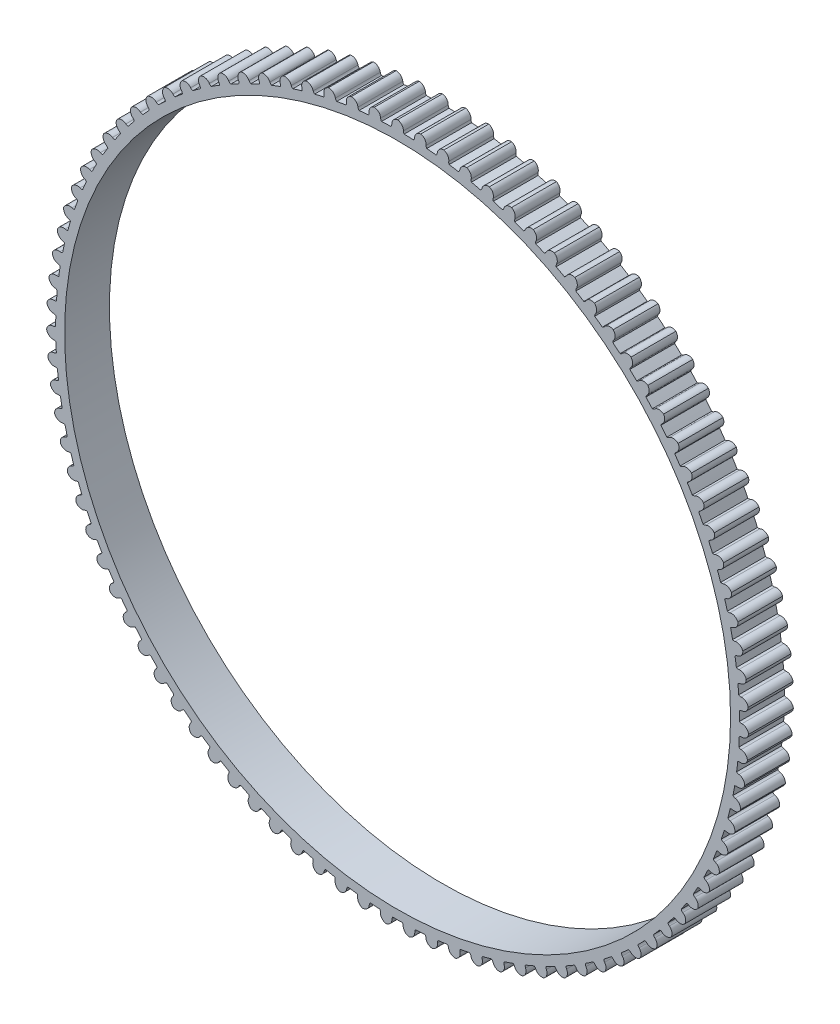
from build123d import *

# Parameters (mm, degrees)
SKETCH1_R      = 44.5516
EXTRUDE1_DEPTH = 6


with BuildPart() as part:
    # Sketch1 → Extrude1 (new body)
    with BuildSketch(Plane.XY):
        with BuildLine():
            ThreePointArc((1.512467656, 45.720390011), (1.196213111, 45.729757219), (0.879901343, 45.736936876))
            ThreePointArc((0.879901343, 45.736936876), (0.802731173, 45.892155239), (0.777675809, 46.063678427))
            ThreePointArc((0.777675809, 46.063678427), (0.559737338, 46.661659663), (0, 46.9646))
            ThreePointArc((0, 46.9646), (-0.559737396, 46.661659691), (-0.777675895, 46.063678426))
            ThreePointArc((-0.777675895, 46.063678426), (-0.802731266, 45.892155234), (-0.879901451, 45.736936874))
            ThreePointArc((-0.879901451, 45.736936874), (-1.196213165, 45.729757218), (-1.512467656, 45.720390011))
            ThreePointArc((-1.512467656, 45.720390011), (-1.828679241, 45.708834522), (-2.144803332, 45.695092076))
            ThreePointArc((-2.144803332, 45.695092076), (-2.232063251, 45.844870852), (-2.268399903, 46.014363103))
            ThreePointArc((-2.268399903, 46.014363103), (-2.525382809, 46.596633248), (-3.103917856, 46.861917877))
            ThreePointArc((-3.103917856, 46.861917877), (-3.642409955, 46.522646537), (-3.820351029, 45.911568999))
            ThreePointArc((-3.820351029, 45.911568999), (-3.834015551, 45.738764897), (-3.900758541, 45.578785679))
            ThreePointArc((-3.900758541, 45.578785679), (-4.215933462, 45.550713784), (-4.53090667, 45.520462497))
            ThreePointArc((-4.53090667, 45.520462497), (-4.845633899, 45.488036375), (-5.160129329, 45.453434265))
            ThreePointArc((-5.160129329, 45.453434265), (-5.257097432, 45.59711851), (-5.304556481, 45.763838676))
            ThreePointArc((-5.304556481, 45.763838676), (-5.5994601, 46.327851612), (-6.19426307, 46.55432051))
            ThreePointArc((-6.19426307, 46.55432051), (-6.709155184, 46.180201686), (-6.84632074, 45.558699963))
            ThreePointArc((-6.84632074, 45.558699963), (-6.848534662, 45.385370578), (-6.904558608, 45.221330051))
            ThreePointArc((-6.904558608, 45.221330051), (-7.21718915, 45.172489437), (-7.529474384, 45.121487527))
            ThreePointArc((-7.529474384, 45.121487527), (-7.84137044, 45.068331795), (-8.152891393, 45.013020151))
            ThreePointArc((-8.152891393, 45.013020151), (-8.259143664, 45.14998157), (-8.317517582, 45.313200628))
            ThreePointArc((-8.317517582, 45.313200628), (-8.649052376, 45.856490068), (-9.257522347, 46.043152945))
            ThreePointArc((-9.257522347, 46.043152945), (-9.746562983, 45.635822564), (-9.842353232, 45.006614323))
            ThreePointArc((-9.842353232, 45.006614323), (-9.833106874, 44.833517582), (-9.878166796, 44.666133053))
            ThreePointArc((-9.878166796, 44.666133053), (-10.186885907, 44.596737287), (-10.495117623, 44.525207773))
            ThreePointArc((-10.495117623, 44.525207773), (-10.802818664, 44.451554867), (-11.110002937, 44.375775553))
            ThreePointArc((-11.110002937, 44.375775553), (-11.225074761, 44.505415248), (-11.294108295, 44.664419482))
            ThreePointArc((-11.294108295, 44.664419482), (-11.660824547, 45.184609761), (-12.280300835, 45.330650388))
            ThreePointArc((-12.280300835, 45.330650388), (-12.741351542, 44.891889601), (-12.795347618, 44.25772621))
            ThreePointArc((-12.795347618, 44.25772621), (-12.774681411, 44.08561902), (-12.808580274, 43.91562242))
            ThreePointArc((-12.808580274, 43.91562242), (-13.112038003, 43.825974953), (-13.414868382, 43.734230615))
            ThreePointArc((-13.414868382, 43.734230615), (-13.717028911, 43.640402599), (-14.018533265, 43.544486979))
            ThreePointArc((-14.018533265, 43.544486979), (-14.141921462, 43.66623807), (-14.221312746, 43.820332194))
            ThreePointArc((-14.221312746, 43.820332194), (-14.6216069, 44.315148652), (-15.249380691, 44.41992843))
            ThreePointArc((-15.249380691, 44.41992843), (-15.680425414, 43.951655827), (-15.692391205, 43.315310321))
            ThreePointArc((-15.692391205, 43.315310321), (-15.660395517, 43.144945264), (-15.682985089, 42.973079944))
            ThreePointArc((-15.682985089, 42.973079944), (-15.979854493, 42.863572781), (-16.275959335, 42.752014793))
            ThreePointArc((-16.275959335, 42.752014793), (-16.57125808, 42.638421955), (-16.865764114, 42.522789443))
            ThreePointArc((-16.865764114, 42.522789443), (-16.99692914, 42.636119542), (-17.086331015, 42.784629744))
            ThreePointArc((-17.086331015, 42.784629744), (-17.518452685, 43.251908673), (-18.151778886, 43.314969427))
            ThreePointArc((-18.151778886, 43.314969427), (-18.550932774, 42.819232645), (-18.520815957, 42.183487602))
            ThreePointArc((-18.520815957, 42.183487602), (-18.477630697, 42.015609639), (-18.488812201, 41.842627123))
            ThreePointArc((-18.488812201, 41.842627123), (-18.777795146, 41.713739111), (-19.06587966, 41.582855289))
            ThreePointArc((-19.06587966, 41.582855289), (-19.353025355, 41.44999434), (-19.639245268, 41.315150568))
            ThreePointArc((-19.639245268, 41.315150568), (-19.77761357, 41.419564113), (-19.876635106, 41.561840993))
            ThreePointArc((-19.876635106, 41.561840993), (-20.338694734, 41.999539103), (-20.97480397, 42.020605083))
            ThreePointArc((-20.97480397, 42.020605083), (-21.340321625, 41.499571853), (-21.268253894, 40.867207224))
            ThreePointArc((-21.268253894, 40.867207224), (-21.2140679, 40.702550444), (-21.213792442, 40.52920714))
            ThreePointArc((-21.213792442, 40.52920714), (-21.493625278, 40.381501874), (-21.772429743, 40.231864538))
            ThreePointArc((-21.772429743, 40.231864538), (-22.050166773, 40.080316446), (-22.326849, 39.926851052))
            ThreePointArc((-22.326849, 39.926851052), (-22.471815529, 40.021891468), (-22.580023729, 40.157312886))
            ThreePointArc((-22.580023729, 40.157312886), (-23.070000847, 40.563516234), (-23.706111573, 40.542495326))
            ThreePointArc((-23.706111573, 40.542495326), (-24.03639468, 39.998443993), (-23.922691168, 39.372224947))
            ThreePointArc((-23.922691168, 39.372224947), (-23.857741382, 39.211509352), (-23.846010165, 39.038563246))
            ThreePointArc((-23.846010165, 39.038563246), (-24.115469255, 38.872686603), (-24.383774531, 38.704950081))
            ThreePointArc((-24.383774531, 38.704950081), (-24.650888422, 38.535377527), (-24.916823101, 38.363961575))
            ThreePointArc((-24.916823101, 38.363961575), (-25.067753956, 38.449213274), (-25.184675654, 38.577187068))
            ThreePointArc((-25.184675654, 38.577187068), (-25.700427715, 38.95011943), (-26.333758382, 38.887103551))
            ThreePointArc((-26.333758382, 38.887103551), (-26.627362697, 38.322413114), (-26.4725206, 37.705077948))
            ThreePointArc((-26.4725206, 37.705077948), (-26.397091031, 37.549006307), (-26.373955354, 37.377213649))
            ThreePointArc((-26.373955354, 37.377213649), (-26.631862422, 37.193890965), (-26.888495277, 37.008788725))
            ThreePointArc((-26.888495277, 37.008788725), (-27.143818009, 36.821933206), (-27.397842275, 36.633316255))
            ThreePointArc((-27.397842275, 36.633316255), (-27.554077473, 36.708406454), (-27.679201399, 36.828373026))
            ThreePointArc((-27.679201399, 36.828373026), (-28.218473152, 37.166403664), (-28.846254366, 37.061668368))
            ThreePointArc((-28.846254366, 37.061668368), (-29.101896031, 36.478808074), (-28.906592435, 35.873056237))
            ThreePointArc((-28.906592435, 35.873056237), (-28.821012918, 35.722311011), (-28.786573946, 35.552423006))
            ThreePointArc((-28.786573946, 35.552423006), (-29.03180123, 35.352455905), (-29.275639475, 35.150797352))
            ThreePointArc((-29.275639475, 35.150797352), (-29.518054586, 34.947475941), (-29.759057655, 34.742482764))
            ThreePointArc((-29.759057655, 34.742482764), (-29.919914021, 34.807083113), (-30.05269304, 34.91851788))
            ThreePointArc((-30.05269304, 34.91851788), (-30.613126386, 35.220168671), (-31.232613019, 35.074171938))
            ThreePointArc((-31.232613019, 35.074171938), (-31.449174179, 34.475690487), (-31.214263096, 33.884170778))
            ThreePointArc((-31.214263096, 33.884170778), (-31.118907847, 33.739411138), (-31.073316175, 33.572170663))
            ThreePointArc((-31.073316175, 33.572170663), (-31.304791358, 33.35643355), (-31.53476875, 33.139100486))
            ThreePointArc((-31.53476875, 33.139100486), (-31.76321622, 32.920202255), (-31.990144248, 32.699729236))
            ThreePointArc((-31.990144248, 32.699729236), (-32.154918396, 32.753557253), (-32.2947719, 32.855972939))
            ThreePointArc((-32.2947719, 32.855972939), (-32.873916207, 33.119924842), (-33.482399403, 32.933305079))
            ThreePointArc((-33.482399403, 32.933305079), (-33.65893309, 32.321819478), (-33.385441727, 31.747118462))
            ThreePointArc((-33.385441727, 31.747118462), (-33.280727711, 31.608977404), (-33.224182699, 31.44511576))
            ThreePointArc((-33.224182699, 31.44511576), (-33.440893599, 31.214551999), (-33.656004506, 30.982494765))
            ThreePointArc((-33.656004506, 30.982494765), (-33.869485392, 30.748976901), (-34.08134608, 30.513988112))
            ThreePointArc((-34.08134608, 30.513988112), (-34.249317496, 30.556808421), (-34.39563394, 30.649757189))
            ThreePointArc((-34.39563394, 30.649757189), (-34.990956757, 30.874856009), (-35.585775772, 30.648429256))
            ThreePointArc((-35.585775772, 30.648429256), (-35.72151005, 30.026613376), (-35.410634316, 29.471244075))
            ThreePointArc((-35.410634316, 29.471244075), (-35.297019421, 29.340325655), (-35.229768325, 29.180559366))
            ThreePointArc((-35.229768325, 29.180559366), (-35.43076732, 28.936177154), (-35.630071116, 28.690410478))
            ThreePointArc((-35.630071116, 28.690410478), (-35.827651922, 28.443294094), (-36.023518857, 28.194817082))
            ThreePointArc((-36.023518857, 28.194817082), (-36.193953044, 28.226442441), (-36.346092624, 28.309517849))
            ThreePointArc((-36.346092624, 28.309517849), (-36.954990756, 28.494779286), (-37.533544599, 28.22953565))
            ThreePointArc((-37.533544599, 28.22953565), (-37.627885936, 27.600108533), (-37.28098521, 27.066499436))
            ThreePointArc((-37.28098521, 27.066499436), (-37.158966245, 26.943376127), (-37.081303138, 26.788403811))
            ThreePointArc((-37.081303138, 26.788403811), (-37.265711311, 26.531271768), (-37.448336492, 26.272870326))
            ThreePointArc((-37.448336492, 26.272870326), (-37.629153246, 26.013236), (-37.808169952, 25.752357291))
            ThreePointArc((-37.808169952, 25.752357291), (-37.980321644, 25.77264941), (-38.137619093, 25.84548819))
            ThreePointArc((-38.137619093, 25.84548819), (-38.757429984, 25.990102143), (-39.317188785, 25.687201467))
            ThreePointArc((-39.317188785, 25.687201467), (-39.369724651, 25.052915439), (-38.988315842, 24.543399881))
            ThreePointArc((-38.988315842, 24.543399881), (-38.858426365, 24.428610071), (-38.770690847, 24.279109382))
            ThreePointArc((-38.770690847, 24.279109382), (-38.937701828, 24.010351882), (-39.10284982, 23.740445597))
            ThreePointArc((-39.10284982, 23.740445597), (-39.266111857, 23.469428643), (-39.427495539, 23.197288993))
            ThreePointArc((-39.427495539, 23.197288993), (-39.600611962, 23.20615914), (-39.762379458, 23.268442787))
            ThreePointArc((-39.762379458, 23.268442787), (-40.390392831, 23.371776897), (-40.928908908, 23.032543688))
            ThreePointArc((-40.928908908, 23.032543688), (-40.939409577, 22.396172319), (-40.525160489, 21.912978284))
            ThreePointArc((-40.525160489, 21.912978284), (-40.387968473, 21.807023919), (-40.29054419, 21.663648586))
            ThreePointArc((-40.29054419, 21.663648586), (-40.439427683, 21.384440836), (-40.586376335, 21.104209939))
            ThreePointArc((-40.586376335, 21.104209939), (-40.731369751, 20.822995446), (-40.874414721, 20.540784854))
            ThreePointArc((-40.874414721, 20.540784854), (-41.047738879, 20.538194241), (-41.213269054, 20.589650405))
            ThreePointArc((-41.213269054, 20.589650405), (-41.846738767, 20.651252817), (-42.361657327, 20.277170456))
            ThreePointArc((-42.361657327, 20.277170456), (-42.330076882, 19.641496437), (-41.884798921, 19.186736808))
            ThreePointArc((-41.884798921, 19.186736808), (-41.740904271, 19.090081199), (-41.634217234, 18.953458166))
            ThreePointArc((-41.634217234, 18.953458166), (-41.764322209, 18.665021071), (-41.892428953, 18.375690941))
            ThreePointArc((-41.892428953, 18.375690941), (-42.018519729, 18.085508588), (-42.142600486, 17.794461088))
            ThreePointArc((-42.142600486, 17.794461088), (-42.315374479, 17.780421045), (-42.48394351, 17.82082472))
            ThreePointArc((-42.48394351, 17.82082472), (-43.120099562, 17.840426062), (-43.609168996, 17.433130317))
            ThreePointArc((-43.609168996, 17.433130317), (-43.53564553, 16.800933288), (-43.061285783, 16.376596614))
            ThreePointArc((-43.061285783, 16.376596614), (-42.911317715, 16.289662411), (-42.79583444, 16.160389096))
            ThreePointArc((-42.79583444, 16.160389096), (-42.906591981, 15.863983918), (-43.015296638, 15.566819723))
            ThreePointArc((-43.015296638, 15.566819723), (-43.121933412, 15.268938403), (-43.226507383, 14.970326671))
            ThreePointArc((-43.226507383, 14.970326671), (-43.397975712, 14.944898591), (-43.568846491, 14.974073103))
            ThreePointArc((-43.568846491, 14.974073103), (-44.204907133, 14.951587664), (-44.665988865, 14.512859534))
            ThreePointArc((-44.665988865, 14.512859534), (-44.550843878, 13.886903933), (-44.0494766, 13.494845729))
            ThreePointArc((-44.0494766, 13.494845729), (-43.894090885, 13.418013075), (-43.770316351, 13.296654756))
            ThreePointArc((-43.770316351, 13.296654756), (-43.861242143, 12.9935776), (-43.950069376, 12.689878762))
            ThreePointArc((-43.950069376, 12.689878762), (-44.036785852, 12.385601036), (-44.121395761, 12.080730825))
            ThreePointArc((-44.121395761, 12.080730825), (-44.29080864, 12.044025898), (-44.463233992, 12.061843674))
            ThreePointArc((-44.463233992, 12.061843674), (-45.096417893, 11.997369777), (-45.52749573, 11.529127709))
            ThreePointArc((-45.52749573, 11.529127709), (-45.371232721, 10.91215068), (-44.845050263, 10.554085318))
            ThreePointArc((-44.845050263, 10.554085318), (-44.684926364, 10.487690181), (-44.553401805, 10.374777528))
            ThreePointArc((-44.553401805, 10.374777528), (-44.624098253, 10.066353674), (-44.692659643, 9.75744819))
            ThreePointArc((-44.692659643, 9.75744819), (-44.759076631, 9.448104586), (-44.823352501, 9.138309017))
            ThreePointArc((-44.823352501, 9.138309017), (-44.989969131, 9.090487744), (-45.163195084, 9.096870872))
            ThreePointArc((-45.163195084, 9.096870872), (-45.790733491, 8.990690445), (-46.189922439, 8.494981943))
            ThreePointArc((-46.189922439, 8.494981943), (-45.993224707, 7.889681369), (-45.444527931, 7.567174577))
            ThreePointArc((-45.444527931, 7.567174577), (-45.28036603, 7.511507287), (-45.141666569, 7.407534038))
            ThreePointArc((-45.141666569, 7.407534038), (-45.191824535, 7.095112143), (-45.239820281, 6.78235078))
            ThreePointArc((-45.239820281, 6.78235078), (-45.285647357, 6.469293979), (-45.329308126, 6.155927709))
            ThreePointArc((-45.329308126, 6.155927709), (-45.492399934, 6.097199201), (-45.665669015, 6.092119768))
            ThreePointArc((-45.665669015, 6.092119768), (-46.284817863, 5.944697111), (-46.650372371, 5.423689781))
            ThreePointArc((-46.650372371, 5.423689781), (-46.414100025, 4.832712488), (-45.845288242, 4.547174508))
            ThreePointArc((-45.845288242, 4.547174508), (-45.677806176, 4.502478482), (-45.532538311, 4.407899286))
            ThreePointArc((-45.532538311, 4.407899286), (-45.561938468, 4.092845493), (-45.589158695, 3.777595876))
            ThreePointArc((-45.589158695, 3.777595876), (-45.61419547, 3.462194795), (-45.63705022, 3.146628095))
            ThreePointArc((-45.63705022, 3.146628095), (-45.795904047, 3.077249156), (-45.968458595, 3.060729374))
            ThreePointArc((-45.968458595, 3.060729374), (-46.576510503, 2.872709129), (-46.906832093, 2.328681205))
            ThreePointArc((-46.906832093, 2.328681205), (-46.632018292, 1.754611385), (-46.045578771, 1.507290801))
            ThreePointArc((-46.045578771, 1.507290801), (-45.875508898, 1.473761485), (-45.724307848, 1.388989913))
            ThreePointArc((-45.724307848, 1.388989913), (-45.732821636, 1.072681871), (-45.739147319, 0.756322506))
            ThreePointArc((-45.739147319, 0.756322506), (-45.743284311, 0.439956314), (-45.745233105, 0.123569077))
            ThreePointArc((-45.745233105, 0.123569077), (-45.899154323, 0.043843084), (-46.070239801, 0.015955189))
            ThreePointArc((-46.070239801, 0.015955189), (-46.664535913, -0.211840479), (-46.958180174, -0.776510102))
            ThreePointArc((-46.958180174, -0.776510102), (-46.646026608, -1.331162186), (-46.044523701, -1.539183906))
            ThreePointArc((-46.044523701, -1.539183906), (-45.872609691, -1.561399896), (-45.716136621, -1.635993161))
            ThreePointArc((-45.716136621, -1.635993161), (-45.703726811, -1.952172317), (-45.689130288, -2.26825807))
            ThreePointArc((-45.689130288, -2.26825807), (-45.67234941, -2.584205983), (-45.653383725, -2.900030277))
            ThreePointArc((-45.653383725, -2.900030277), (-45.801699277, -2.989754702), (-45.97056757, -3.028888763))
            ThreePointArc((-45.97056757, -3.028888763), (-46.548509181, -3.295463763), (-46.80419208, -3.878305928))
            ThreePointArc((-46.80419208, -3.878305928), (-46.456063718, -4.411114925), (-45.842127644, -4.578928152))
            ThreePointArc((-45.842127644, -4.578928152), (-45.669121235, -4.589733673), (-45.50806036, -4.653822452))
            ThreePointArc((-45.50806036, -4.653822452), (-45.474781218, -4.968490151), (-45.439326316, -5.28292013))
            ThreePointArc((-45.439326316, -5.28292013), (-45.401700945, -5.597068206), (-45.361903714, -5.910948537))
            ThreePointArc((-45.361903714, -5.910948537), (-45.503965053, -6.010279052), (-45.669877744, -6.060488156))
            ThreePointArc((-45.669877744, -6.060488156), (-46.228937662, -6.364676822), (-46.445541164, -6.963142909))
            ThreePointArc((-46.445541164, -6.963142909), (-46.062960282, -7.47177898), (-45.439275627, -7.598649911))
            ThreePointArc((-45.439275627, -7.598649911), (-45.265933331, -7.597997712), (-45.10098893, -7.651301762))
            ThreePointArc((-45.10098893, -7.651301762), (-45.046985976, -7.963082042), (-44.990827731, -8.274481325))
            ThreePointArc((-44.990827731, -8.274481325), (-44.932522393, -8.585455873), (-44.87206764, -8.896019722))
            ThreePointArc((-44.87206764, -8.896019722), (-45.007253568, -9.004521981), (-45.169485163, -9.065586575))
            ThreePointArc((-45.169485163, -9.065586575), (-45.70721876, -9.406058768), (-45.883795713, -10.017531838))
            ThreePointArc((-45.883795713, -10.017531838), (-45.468435241, -10.499770846), (-44.837729219, -10.585144707))
            ThreePointArc((-44.837729219, -10.585144707), (-44.664809018, -10.573037641), (-44.496702352, -10.615323876))
            ThreePointArc((-44.496702352, -10.615323876), (-44.422211727, -10.922853402), (-44.345595705, -11.229860318))
            ThreePointArc((-44.345595705, -11.229860318), (-44.266865354, -11.536301526), (-44.186017431, -11.842190877))
            ThreePointArc((-44.186017431, -11.842190877), (-44.313736814, -11.959390427), (-44.471577916, -12.031043492))
            ThreePointArc((-44.471577916, -12.031043492), (-44.985633821, -12.406310413), (-45.121412098, -13.028116649))
            ThreePointArc((-45.121412098, -13.028116649), (-44.675088301, -13.481849886), (-44.040118829, -13.525353359))
            ThreePointArc((-44.040118829, -13.525353359), (-43.868376859, -13.501844366), (-43.697843015, -13.53292788))
            ThreePointArc((-43.697843015, -13.53292788), (-43.603190449, -13.834861902), (-43.506451671, -14.13613399))
            ThreePointArc((-43.506451671, -14.13613399), (-43.407640576, -14.436701868), (-43.30675301, -14.736579145))
            ThreePointArc((-43.30675301, -14.736579145), (-43.426447365, -14.861963501), (-43.579207774, -14.943891716))
            ThreePointArc((-43.579207774, -14.943891716), (-44.067338151, -15.352312419), (-44.161724029, -15.98173282))
            ThreePointArc((-44.161724029, -15.98173282), (-43.686388567, -16.404976227), (-43.049932205, -16.406419082))
            ThreePointArc((-43.049932205, -16.406419082), (-42.880119451, -16.371610961), (-42.707904129, -16.391355834))
            ThreePointArc((-42.707904129, -16.391355834), (-42.593503513, -16.686374072), (-42.477064994, -16.980593944))
            ThreePointArc((-42.477064994, -16.980593944), (-42.35860523, -17.273974186), (-42.238119177, -17.566528101))
            ThreePointArc((-42.238119177, -17.566528101), (-42.34926511, -17.69954899), (-42.496276845, -17.791394104))
            ThreePointArc((-42.496276845, -17.791394104), (-42.956347224, -18.231182669), (-43.008927977, -18.865464941))
            ThreePointArc((-43.008927977, -18.865464941), (-42.506659372, -19.256367781), (-41.871499181, -19.215743708))
            ThreePointArc((-41.871499181, -19.215743708), (-41.70435819, -19.169788667), (-41.531214445, -19.178108559))
            ThreePointArc((-41.531214445, -19.178108559), (-41.397566023, -19.464920973), (-41.261936919, -19.750802082))
            ThreePointArc((-41.261936919, -19.750802082), (-41.12434648, -20.03571181), (-40.984788797, -20.319663099))
            ThreePointArc((-40.984788797, -20.319663099), (-41.086900295, -20.459738855), (-41.22752051, -20.561099253))
            ThreePointArc((-41.22752051, -20.561099253), (-41.65751912, -21.030332596), (-41.668064826, -21.666703183))
            ThreePointArc((-41.668064826, -21.666703183), (-41.14105937, -22.023556139), (-40.509972745, -21.941042777))
            ThreePointArc((-40.509972745, -21.941042777), (-40.346234382, -21.884141764), (-40.172919327, -21.881000294))
            ThreePointArc((-40.172919327, -21.881000294), (-40.020607511, -22.158352728), (-39.866380893, -22.434644987))
            ThreePointArc((-39.866380893, -22.434644987), (-39.710261428, -22.709838364), (-39.552242362, -22.983945381))
            ThreePointArc((-39.552242362, -22.983945381), (-39.644872918, -23.130463487), (-39.778486717, -23.240895946))
            ThreePointArc((-39.778486717, -23.240895946), (-40.176533284, -23.73752223), (-40.14499783, -24.373198445))
            ThreePointArc((-40.14499783, -24.373198445), (-39.595559984, -24.694441089), (-38.971306506, -24.570399248))
            ThreePointArc((-38.971306506, -24.570399248), (-38.811686756, -24.502801078), (-38.638958255, -24.488211983))
            ThreePointArc((-38.638958255, -24.488211983), (-38.468649064, -24.754891644), (-38.296499326, -25.020386898))
            ThreePointArc((-38.296499326, -25.020386898), (-38.122533506, -25.284660573), (-37.946744036, -25.547724717))
            ThreePointArc((-37.946744036, -25.547724717), (-38.029488599, -25.700044488), (-38.155511723, -25.819066114))
            ThreePointArc((-38.155511723, -25.819066114), (-38.519865691, -26.340913718), (-38.446386972, -26.973115911))
            ThreePointArc((-38.446386972, -26.973115911), (-37.876919288, -27.257343531), (-37.262228659, -27.092315614))
            ThreePointArc((-37.262228659, -27.092315614), (-37.1074255, -27.014315877), (-36.936038849, -26.988342952))
            ThreePointArc((-36.936038849, -26.988342952), (-36.748477003, -27.243183718), (-36.559156912, -27.496721023))
            ThreePointArc((-36.559156912, -27.496721023), (-36.368105444, -27.748919394), (-36.175314253, -27.999790354))
            ThreePointArc((-36.175314253, -27.999790354), (-36.247811003, -28.157245733), (-36.365692385, -28.284336076))
            ThreePointArc((-36.365692385, -28.284336076), (-36.694760526, -28.829123093), (-36.579659846, -29.455086805))
            ThreePointArc((-36.579659846, -29.455086805), (-35.992652461, -29.701056545), (-35.390212566, -29.495764178))
            ThreePointArc((-35.390212566, -29.495764178), (-35.240902913, -29.407703946), (-35.071607543, -29.370460764))
            ThreePointArc((-35.071607543, -29.370460764), (-34.867613203, -29.612348281), (-34.661950607, -29.852818983))
            ThreePointArc((-34.661950607, -29.852818983), (-34.454648911, -30.091839252), (-34.245699025, -30.329420032))
            ThreePointArc((-34.245699025, -30.329420032), (-34.307630952, -30.491322507), (-34.416855126, -30.625925833))
            ThreePointArc((-34.416855126, -30.625925833), (-34.709198509, -31.191270048), (-34.552979175, -31.808258099))
            ThreePointArc((-34.552979175, -31.808258099), (-33.950998923, -32.014894396), (-33.363444079, -31.77023527))
            ThreePointArc((-33.363444079, -31.77023527), (-33.220280825, -31.672499608), (-33.053817022, -31.624149024))
            ThreePointArc((-33.053817022, -31.624149024), (-32.834282201, -31.852025579), (-32.613176412, -32.078378162))
            ThreePointArc((-32.613176412, -32.078378162), (-32.390530965, -32.303175153), (-32.166336069, -32.526426872))
            ThreePointArc((-32.166336069, -32.526426872), (-32.21743236, -32.692068486), (-32.317521717, -32.833596208))
            ThreePointArc((-32.317521717, -32.833596208), (-32.571861999, -33.417025515), (-32.375207118, -34.022339973))
            ThreePointArc((-32.375207118, -34.022339973), (-31.760886306, -34.18873926), (-31.19078574, -33.905783207))
            ThreePointArc((-31.19078574, -33.905783207), (-31.054394901, -33.798799489), (-30.891490568, -33.739552926))
            ThreePointArc((-30.891490568, -33.739552926), (-30.657375238, -33.952422074), (-30.421793093, -34.163666755))
            ThreePointArc((-30.421793093, -34.163666755), (-30.184777468, -34.373257488), (-29.946317909, -34.581203924))
            ThreePointArc((-29.946317909, -34.581203924), (-29.986355134, -34.749860368), (-30.076872008, -34.897693621))
            ThreePointArc((-30.076872008, -34.897693621), (-30.292097024, -35.496656832), (-30.055866517, -36.087650811))
            ThreePointArc((-30.055866517, -36.087650811), (-29.431891413, -36.213085465), (-28.881738031, -35.893069781))
            ThreePointArc((-28.881738031, -35.893069781), (-28.75271601, -35.777305818), (-28.594083486, -35.707422348))
            ThreePointArc((-28.594083486, -35.707422348), (-28.346411373, -35.904353266), (-28.097383014, -36.099566326))
            ThreePointArc((-28.097383014, -36.099566326), (-27.84703362, -36.293034314), (-27.595352121, -36.48476617))
            ThreePointArc((-27.595352121, -36.48476617), (-27.624155207, -36.655699951), (-27.704703791, -36.809192299))
            ThreePointArc((-27.704703791, -36.809192299), (-27.879872416, -37.4210703), (-27.60509926, -37.995159534))
            ThreePointArc((-27.60509926, -37.995159534), (-26.974198349, -38.079081062), (-26.44639783, -37.723405093))
            ThreePointArc((-26.44639783, -37.723405093), (-26.325308807, -37.599367093), (-26.171641752, -37.519152298))
            ThreePointArc((-26.171641752, -37.519152298), (-25.911495863, -37.699283856), (-25.650110229, -37.877611678))
            ThreePointArc((-25.650110229, -37.877611678), (-25.387521779, -38.054110935), (-25.123718879, -38.228789817))
            ThreePointArc((-25.123718879, -38.228789817), (-25.141161877, -38.401253486), (-25.211389953, -38.559733745))
            ThreePointArc((-25.211389953, -38.559733745), (-25.345736219, -39.18185095), (-25.033621927, -39.736525092))
            ThreePointArc((-25.033621927, -39.736525092), (-24.398553977, -39.778566526), (-23.89541426, -39.388785552))
            ThreePointArc((-23.89541426, -39.388785552), (-23.782787727, -39.257015901), (-23.634758088, -39.166820541))
            ThreePointArc((-23.634758088, -39.166820541), (-23.363275975, -39.329365071), (-23.090676037, -39.490027872))
            ThreePointArc((-23.090676037, -39.490027872), (-22.816996765, -39.648786612), (-22.542226006, -39.805648693))
            ThreePointArc((-22.542226006, -39.805648693), (-22.548232643, -39.97888811), (-22.607833122, -40.141663287))
            ThreePointArc((-22.607833122, -40.141663287), (-22.700769567, -40.771299334), (-22.352678935, -41.304132936))
            ThreePointArc((-22.352678935, -41.304132936), (-21.716220938, -41.30411044), (-21.239942124, -40.881928875))
            ThreePointArc((-21.239942124, -40.881928875), (-21.136270567, -40.743003768), (-20.994525641, -40.643222243))
            ThreePointArc((-20.994525641, -40.643222243), (-20.712894426, -40.787468978), (-20.430272195, -40.929764221))
            ThreePointArc((-20.430272195, -40.929764221), (-20.146698829, -41.070088233), (-19.862161715, -41.208447595))
            ThreePointArc((-19.862161715, -41.208447595), (-19.856705725, -41.381705228), (-19.905417988, -41.548063548))
            ThreePointArc((-19.905417988, -41.548063548), (-19.956538226, -42.182465201), (-19.573993365, -42.691128316))
            ThreePointArc((-19.573993365, -42.691128316), (-18.938928389, -42.649041989), (-18.491593125, -42.196305924))
            ThreePointArc((-18.491593125, -42.196305924), (-18.397329874, -42.050832846), (-18.262489475, -41.941901475))
            ThreePointArc((-18.262489475, -41.941901475), (-17.971940659, -42.067219662), (-17.68053197, -42.190525126))
            ThreePointArc((-17.68053197, -42.190525126), (-17.388304505, -42.311800808), (-17.095245245, -42.43105244))
            ThreePointArc((-17.095245245, -42.43105244), (-17.078350485, -42.603570678), (-17.115961527, -42.772784699))
            ThreePointArc((-17.115961527, -42.772784699), (-17.125042021, -43.409177879), (-16.709715703, -43.891446254))
            ThreePointArc((-16.709715703, -43.891446254), (-16.078820726, -43.807480128), (-15.662385094, -43.326169264))
            ThreePointArc((-15.662385094, -43.326169264), (-15.577942339, -43.174784331), (-15.450596089, -43.057179444))
            ThreePointArc((-15.450596089, -43.057179444), (-15.152400169, -43.163021098), (-14.853479277, -43.2667976))
            ThreePointArc((-14.853479277, -43.2667976), (-14.55387555, -43.368494643), (-14.253575617, -43.468117089))
            ThreePointArc((-14.253575617, -43.468117089), (-14.225315964, -43.639141554), (-14.25166132, -43.810471345))
            ThreePointArc((-14.25166132, -43.810471345), (-14.218662364, -44.446073268), (-13.772370706, -44.899838065))
            ThreePointArc((-13.772370706, -44.899838065), (-13.14840447, -44.774359303), (-12.764689438, -44.26657829))
            ThreePointArc((-12.764689438, -44.26657829), (-12.690436425, -44.109943469), (-12.571141177, -43.984179323))
            ThreePointArc((-12.571141177, -43.984179323), (-12.266602088, -44.070081624), (-11.961476099, -44.153875376))
            ThreePointArc((-11.961476099, -44.153875376), (-11.655806201, -44.235549086), (-11.349578729, -44.315106723))
            ThreePointArc((-11.349578729, -44.315106723), (-11.310077756, -44.483889567), (-11.325042225, -44.656585947))
            ThreePointArc((-11.325042225, -44.656585947), (-11.250108114, -45.288617287), (-10.774802635, -45.711894309))
            ThreePointArc((-10.774802635, -45.711894309), (-10.160493588, -45.545451597), (-9.811177043, -45.013420832))
            ThreePointArc((-9.811177043, -45.013420832), (-9.747438462, -44.852221048), (-9.636715863, -44.718847576))
            ThreePointArc((-9.636715863, -44.718847576), (-9.327165278, -44.784434897), (-9.01716843, -44.847879489))
            ThreePointArc((-9.01716843, -44.847879489), (-8.706768976, -44.909172729), (-8.395953021, -44.96831767))
            ThreePointArc((-8.395953021, -44.96831767), (-8.345383455, -45.134120849), (-8.348901602, -45.307428662))
            ThreePointArc((-8.348901602, -45.307428662), (-8.232360004, -45.933125706), (-7.730119095, -46.32406407))
            ThreePointArc((-7.730119095, -46.32406407), (-7.128153452, -46.117385219), (-6.814762868, -45.563431137))
            ThreePointArc((-6.814762868, -45.563431137), (-6.76181743, -45.398371277), (-6.660151644, -45.257971687))
            ThreePointArc((-6.660151644, -45.257971687), (-6.346943146, -45.302957231), (-6.033430977, -45.345775237))
            ThreePointArc((-6.033430977, -45.345775237), (-5.719659266, -45.386419985), (-5.405613947, -45.424893605))
            ThreePointArc((-5.405613947, -45.424893605), (-5.344196916, -45.586992105), (-5.336253356, -45.760153518))
            ThreePointArc((-5.336253356, -45.760153518), (-5.178613878, -46.376780253), (-4.65163371, -46.733670485))
            ThreePointArc((-4.65163371, -46.733670485), (-4.064643714, -46.48765925), (-3.788549468, -45.914204152))
            ThreePointArc((-3.788549468, -45.914204152), (-3.746628692, -45.746005979), (-3.654464275, -45.599194204))
            ThreePointArc((-3.654464275, -45.599194204), (-3.338967447, -45.623381259), (-3.023310865, -45.645385447))
            ThreePointArc((-3.023310865, -45.645385447), (-2.707538942, -45.665203975), (-2.391637499, -45.682838038))
            ThreePointArc((-2.391637499, -45.682838038), (-2.319641564, -45.840523043), (-2.300271032, -46.012780866))
            ThreePointArc((-2.300271032, -46.012780866), (-2.102222992, -46.61764094), (-1.552807915, -46.93892245))
            ThreePointArc((-1.552807915, -46.93892245), (-0.983360324, -46.654654576), (-0.745769705, -46.064206034))
            ThreePointArc((-0.745769705, -46.064206034), (-0.715056899, -45.893605036), (-0.632796864, -45.741023046))
            ThreePointArc((-0.632796864, -45.741023046), (-0.316391293, -45.74430585), (2.9415e-05, -45.7454))
            ThreePointArc((2.9415e-05, -45.7454), (0.316420762, -45.744305646), (0.632796972, -45.741023044))
            ThreePointArc((0.632796972, -45.741023044), (0.715056991, -45.893605037), (0.745769792, -46.064206031))
            ThreePointArc((0.745769792, -46.064206031), (0.983360381, -46.654654545), (1.552807915, -46.93892245))
            ThreePointArc((1.552807915, -46.93892245), (2.102223051, -46.617640967), (2.300271119, -46.012780863))
            ThreePointArc((2.300271119, -46.012780863), (2.319641655, -45.840523035), (2.391637606, -45.682838033))
            ThreePointArc((2.391637606, -45.682838033), (2.707568359, -45.66520223), (3.023369567, -45.645381559))
            ThreePointArc((3.023369567, -45.645381559), (3.338996838, -45.623379109), (3.654464383, -45.599194195))
            ThreePointArc((3.654464383, -45.599194195), (3.746628784, -45.746005974), (3.788549554, -45.914204144))
            ThreePointArc((3.788549554, -45.914204144), (4.064643769, -46.487659216), (4.65163371, -46.733670485))
            ThreePointArc((4.65163371, -46.733670485), (5.178613939, -46.376780276), (5.336253442, -45.760153509))
            ThreePointArc((5.336253442, -45.760153509), (5.344197007, -45.586992091), (5.405614054, -45.424893592))
            ThreePointArc((5.405614054, -45.424893592), (5.719688504, -45.3864163), (6.033489293, -45.345767477))
            ThreePointArc((6.033489293, -45.345767477), (6.34697233, -45.302953142), (6.66015175, -45.257971672))
            ThreePointArc((6.66015175, -45.257971672), (6.761817522, -45.398371266), (6.814762953, -45.563431124))
            ThreePointArc((6.814762953, -45.563431124), (7.128153504, -46.117385182), (7.730119095, -46.32406407))
            ThreePointArc((7.730119095, -46.32406407), (8.232360066, -45.933125725), (8.348901687, -45.307428647))
            ThreePointArc((8.348901687, -45.307428647), (8.345383545, -45.134120829), (8.395953127, -44.96831765))
            ThreePointArc((8.395953127, -44.96831765), (8.706797907, -44.90916712), (9.017226106, -44.847867893))
            ThreePointArc((9.017226106, -44.847867893), (9.327194127, -44.784428889), (9.636715969, -44.718847553))
            ThreePointArc((9.636715969, -44.718847553), (9.747438553, -44.852221032), (9.811177128, -45.013420812))
            ThreePointArc((9.811177128, -45.013420812), (10.160493637, -45.545451556), (10.774802635, -45.711894309))
            ThreePointArc((10.774802635, -45.711894309), (11.250108177, -45.288617302), (11.325042309, -44.656585927))
            ThreePointArc((11.325042309, -44.656585927), (11.310077845, -44.483889541), (11.349578834, -44.315106696))
            ThreePointArc((11.349578834, -44.315106696), (11.655834697, -44.235541578), (11.961532883, -44.153859993))
            ThreePointArc((11.961532883, -44.153859993), (12.266630478, -44.070073722), (12.571141281, -43.984179293))
            ThreePointArc((12.571141281, -43.984179293), (12.690436515, -44.109943447), (12.764689521, -44.266578265))
            ThreePointArc((12.764689521, -44.266578265), (13.148404517, -44.774359259), (13.772370706, -44.899838066))
            ThreePointArc((13.772370706, -44.899838066), (14.218662427, -44.446073278), (14.251661403, -43.810471319))
            ThreePointArc((14.251661403, -43.810471319), (14.225316051, -43.639141522), (14.253575719, -43.468117056))
            ThreePointArc((14.253575719, -43.468117056), (14.553903488, -43.368485268), (14.85353492, -43.266778497))
            ThreePointArc((14.85353492, -43.266778497), (15.152427975, -43.163011337), (15.45059619, -43.057179408))
            ThreePointArc((15.45059619, -43.057179408), (15.577942427, -43.174784302), (15.662385175, -43.326169234))
            ThreePointArc((15.662385175, -43.326169234), (16.07882077, -43.807480081), (16.709715703, -43.891446254))
            ThreePointArc((16.709715703, -43.891446254), (17.125042085, -43.409177885), (17.115961607, -42.772784668))
            ThreePointArc((17.115961607, -42.772784668), (17.07835057, -42.603570641), (17.095245345, -42.4310524))
            ThreePointArc((17.095245345, -42.4310524), (17.388331762, -42.311789606), (17.680586228, -42.190502388))
            ThreePointArc((17.680586228, -42.190502388), (17.971967759, -42.067208085), (18.262489574, -41.941901432))
            ThreePointArc((18.262489574, -41.941901432), (18.39732996, -42.050832812), (18.491593204, -42.196305889))
            ThreePointArc((18.491593204, -42.196305889), (18.93892843, -42.649041939), (19.573993365, -42.691128316))
            ThreePointArc((19.573993365, -42.691128316), (19.95653829, -42.182465202), (19.905418067, -41.548063511))
            ThreePointArc((19.905418067, -41.548063511), (19.856705807, -41.381705185), (19.862161813, -41.208447548))
            ThreePointArc((19.862161813, -41.208447548), (20.146725286, -41.070075255), (20.430324832, -40.929737947))
            ThreePointArc((20.430324832, -40.929737947), (20.712920701, -40.787455635), (20.994525737, -40.643222193))
            ThreePointArc((20.994525737, -40.643222193), (21.13627065, -40.743003728), (21.2399422, -40.881928834))
            ThreePointArc((21.2399422, -40.881928834), (21.716220975, -41.304110388), (22.352678935, -41.304132936))
            ThreePointArc((22.352678935, -41.304132936), (22.700769632, -40.771299332), (22.607833198, -40.141663245))
            ThreePointArc((22.607833198, -40.141663245), (22.548232722, -39.978888062), (22.5422261, -39.80564864))
            ThreePointArc((22.5422261, -39.80564864), (22.817022306, -39.648771913), (23.090726823, -39.489998176))
            ThreePointArc((23.090726823, -39.489998176), (23.363301311, -39.32935002), (23.634758181, -39.166820485))
            ThreePointArc((23.634758181, -39.166820485), (23.782787807, -39.257015856), (23.895414334, -39.388785507))
            ThreePointArc((23.895414334, -39.388785507), (24.398554011, -39.778566471), (25.033621927, -39.736525092))
            ThreePointArc((25.033621927, -39.736525092), (25.345736284, -39.181850943), (25.211390026, -38.559733699))
            ThreePointArc((25.211390026, -38.559733699), (25.141161952, -38.401253433), (25.123718969, -38.228789758))
            ThreePointArc((25.123718969, -38.228789758), (25.387546293, -38.054094581), (25.650158941, -37.877578691))
            ThreePointArc((25.650158941, -37.877578691), (25.911520149, -37.699267164), (26.171641841, -37.519152236))
            ThreePointArc((26.171641841, -37.519152236), (26.325308884, -37.599367042), (26.4463979, -37.723405042))
            ThreePointArc((26.4463979, -37.723405042), (26.974198378, -38.079081005), (27.60509926, -37.995159534))
            ThreePointArc((27.60509926, -37.995159534), (27.879872479, -37.42107029), (27.704703861, -36.809192248))
            ThreePointArc((27.704703861, -36.809192248), (27.624155279, -36.655699894), (27.595352207, -36.484766105))
            ThreePointArc((27.595352207, -36.484766105), (27.847057, -36.293016375), (28.09742944, -36.099530191))
            ThreePointArc((28.09742944, -36.099530191), (28.346434502, -35.904335005), (28.59408357, -35.707422281))
            ThreePointArc((28.59408357, -35.707422281), (28.752716083, -35.777305763), (28.881738098, -35.893069726))
            ThreePointArc((28.881738098, -35.893069726), (29.43189144, -36.213085406), (30.055866517, -36.087650811))
            ThreePointArc((30.055866517, -36.087650811), (30.292097087, -35.496656817), (30.076872075, -34.897693565))
            ThreePointArc((30.076872075, -34.897693565), (29.986355202, -34.749860305), (29.94631799, -34.581203854))
            ThreePointArc((29.94631799, -34.581203854), (30.184799612, -34.373238043), (30.421837029, -34.163627632))
            ThreePointArc((30.421837029, -34.163627632), (30.65739711, -33.952402325), (30.891490647, -33.739552853))
            ThreePointArc((30.891490647, -33.739552853), (31.054394971, -33.798799428), (31.190785803, -33.905783148))
            ThreePointArc((31.190785803, -33.905783148), (31.760886328, -34.188739199), (32.375207118, -34.022339973))
            ThreePointArc((32.375207118, -34.022339973), (32.571862061, -33.417025496), (32.317521779, -32.833596148))
            ThreePointArc((32.317521779, -32.833596148), (32.217432424, -32.692068419), (32.166336145, -32.526426797))
            ThreePointArc((32.166336145, -32.526426797), (32.390551775, -32.303154287), (32.613217665, -32.07833622))
            ThreePointArc((32.613217665, -32.07833622), (32.83430272, -31.852004428), (33.053817096, -31.624148946))
            ThreePointArc((33.053817096, -31.624148946), (33.220280891, -31.672499544), (33.363444138, -31.770235207))
            ThreePointArc((33.363444138, -31.770235207), (33.950998942, -32.014894334), (34.552979175, -31.808258099))
            ThreePointArc((34.552979175, -31.808258099), (34.70919857, -31.191270025), (34.416855184, -30.625925769))
            ThreePointArc((34.416855184, -30.625925769), (34.307631011, -30.491322437), (34.245699097, -30.329419951))
            ThreePointArc((34.245699097, -30.329419951), (34.454668296, -30.091817056), (34.661988999, -29.852774407))
            ThreePointArc((34.661988999, -29.852774407), (34.867632279, -29.612325819), (35.071607613, -29.370460681))
            ThreePointArc((35.071607613, -29.370460681), (35.240902975, -29.407703877), (35.390212621, -29.495764111))
            ThreePointArc((35.390212621, -29.495764111), (35.992652475, -29.701056482), (36.579659846, -29.455086805))
            ThreePointArc((36.579659846, -29.455086805), (36.694760584, -28.829123066), (36.365692439, -28.284336008))
            ThreePointArc((36.365692439, -28.284336008), (36.247811058, -28.157245659), (36.175314319, -27.999790269))
            ThreePointArc((36.175314319, -27.999790269), (36.36812332, -27.748895966), (36.559192274, -27.496674007))
            ThreePointArc((36.559192274, -27.496674007), (36.748494553, -27.243160045), (36.936038913, -26.988342865))
            ThreePointArc((36.936038913, -26.988342865), (37.107425557, -27.014315804), (37.262228709, -27.092315544))
            ThreePointArc((37.262228709, -27.092315544), (37.876919298, -27.257343467), (38.446386972, -26.973115911))
            ThreePointArc((38.446386972, -26.973115911), (38.519865748, -26.340913687), (38.155511772, -25.819066043))
            ThreePointArc((38.155511772, -25.819066043), (38.029488649, -25.70004441), (37.946744096, -25.547724628))
            ThreePointArc((37.946744096, -25.547724628), (38.122549794, -25.284636014), (38.296531503, -25.020337647))
            ThreePointArc((38.296531503, -25.020337647), (38.468665011, -24.754866863), (38.638958313, -24.488211892))
            ThreePointArc((38.638958313, -24.488211892), (38.811686808, -24.502801002), (38.971306551, -24.570399174))
            ThreePointArc((38.971306551, -24.570399174), (39.595559989, -24.694441024), (40.14499783, -24.373198445))
            ThreePointArc((40.14499783, -24.373198445), (40.176533339, -23.737522195), (39.778486762, -23.240895872))
            ThreePointArc((39.778486762, -23.240895872), (39.644872962, -23.130463406), (39.552242417, -22.983945288))
            ThreePointArc((39.552242417, -22.983945288), (39.710276057, -22.709812782), (39.866409744, -22.434593717))
            ThreePointArc((39.866409744, -22.434593717), (40.020621785, -22.158326947), (40.172919379, -21.8810002))
            ThreePointArc((40.172919379, -21.8810002), (40.346234428, -21.884141685), (40.509972786, -21.9410427))
            ThreePointArc((40.509972786, -21.9410427), (41.141059371, -22.023556074), (41.668064826, -21.666703183))
            ThreePointArc((41.668064826, -21.666703183), (41.657519172, -21.030332558), (41.227520549, -20.561099176))
            ThreePointArc((41.227520549, -20.561099176), (41.086900333, -20.459738771), (40.984788845, -20.319663002))
            ThreePointArc((40.984788845, -20.319663002), (41.124359387, -20.035685318), (41.261962319, -19.750749017))
            ThreePointArc((41.261962319, -19.750749017), (41.397578563, -19.464894305), (41.53121449, -19.178108461))
            ThreePointArc((41.53121449, -19.178108461), (41.704358231, -19.169788584), (41.871499217, -19.215743629))
            ThreePointArc((41.871499217, -19.215743629), (42.506659369, -19.256367717), (43.008927977, -18.865464941))
            ThreePointArc((43.008927977, -18.865464941), (42.956347274, -18.231182628), (42.496276879, -17.791394025))
            ThreePointArc((42.496276879, -17.791394025), (42.349265143, -17.699548904), (42.238119219, -17.566528001))
            ThreePointArc((42.238119219, -17.566528001), (42.358616357, -17.273946899), (42.477086831, -16.980539317))
            ThreePointArc((42.477086831, -16.980539317), (42.593514262, -16.686346633), (42.707904168, -16.391355733))
            ThreePointArc((42.707904168, -16.391355733), (42.880119486, -16.371610876), (43.049932235, -16.406419))
            ThreePointArc((43.049932235, -16.406419), (43.68638856, -16.404976163), (44.161724029, -15.98173282))
            ThreePointArc((44.161724029, -15.98173282), (44.067338198, -15.352312375), (43.579207803, -14.943891635))
            ThreePointArc((43.579207803, -14.943891635), (43.426447392, -14.861963413), (43.306753045, -14.736579042))
            ThreePointArc((43.306753045, -14.736579042), (43.407649876, -14.436673905), (43.50646985, -14.136078039))
            ThreePointArc((43.50646985, -14.136078039), (43.603199361, -13.834833813), (43.697843047, -13.532927777))
            ThreePointArc((43.697843047, -13.532927777), (43.868376889, -13.501844279), (44.040118854, -13.525353276))
            ThreePointArc((44.040118854, -13.525353276), (44.67508829, -13.481849823), (45.121412098, -13.028116649))
            ThreePointArc((45.121412098, -13.028116649), (44.985633865, -12.406310366), (44.47157794, -12.031043409))
            ThreePointArc((44.47157794, -12.031043409), (44.313736835, -11.959390337), (44.186017459, -11.842190773))
            ThreePointArc((44.186017459, -11.842190773), (44.266872786, -11.53627301), (44.345610147, -11.229803289))
            ThreePointArc((44.345610147, -11.229803289), (44.422218764, -10.922824785), (44.496702377, -10.615323771))
            ThreePointArc((44.496702377, -10.615323771), (44.664809042, -10.573037552), (44.837729238, -10.585144623))
            ThreePointArc((44.837729238, -10.585144623), (45.468435225, -10.499770784), (45.883795713, -10.017531838))
            ThreePointArc((45.883795713, -10.017531838), (45.707218801, -9.406058718), (45.169485181, -9.065586491))
            ThreePointArc((45.169485181, -9.065586491), (45.007253583, -9.00452189), (44.872067661, -8.896019617))
            ThreePointArc((44.872067661, -8.896019617), (44.932527924, -8.585426928), (44.990838373, -8.274423465))
            ThreePointArc((44.990838373, -8.274423465), (45.046991106, -7.963053023), (45.100988949, -7.651301656))
            ThreePointArc((45.100988949, -7.651301656), (45.265933349, -7.597997622), (45.43927564, -7.598649826))
            ThreePointArc((45.43927564, -7.598649826), (46.062960263, -7.471778918), (46.445541164, -6.963142909))
            ThreePointArc((46.445541164, -6.963142909), (46.228937698, -6.364676769), (45.669877757, -6.06048807))
            ThreePointArc((45.669877757, -6.06048807), (45.503965062, -6.010278961), (45.361903728, -5.91094843))
            ThreePointArc((45.361903728, -5.91094843), (45.40170455, -5.597038958), (45.43933311, -5.282861694))
            ThreePointArc((45.43933311, -5.282861694), (45.474784418, -4.968460856), (45.508060371, -4.653822345))
            ThreePointArc((45.508060371, -4.653822345), (45.669121247, -4.589733581), (45.842127652, -4.578928066))
            ThreePointArc((45.842127652, -4.578928066), (46.456063695, -4.411114865), (46.80419208, -3.878305928))
            ThreePointArc((46.80419208, -3.878305928), (46.548509214, -3.295463707), (45.970567577, -3.028888677))
            ThreePointArc((45.970567577, -3.028888677), (45.80169928, -2.98975461), (45.653383732, -2.90003017))
            ThreePointArc((45.653383732, -2.90003017), (45.672351074, -2.584176561), (45.689133205, -2.268199312))
            ThreePointArc((45.689133205, -2.268199312), (45.703728069, -1.952142875), (45.716136625, -1.635993053))
            ThreePointArc((45.716136625, -1.635993053), (45.872609698, -1.561399804), (46.044523703, -1.53918382))
            ThreePointArc((46.044523703, -1.53918382), (46.646026581, -1.331162129), (46.958180174, -0.776510103))
            ThreePointArc((46.958180174, -0.776510103), (46.664535942, -0.211840422), (46.070239802, 0.015955276))
            ThreePointArc((46.070239802, 0.015955276), (45.89915432, 0.043843176), (45.745233105, 0.123569184))
            ThreePointArc((45.745233105, 0.123569184), (45.743284028, 0.439985782), (45.739146346, 0.756381328))
            ThreePointArc((45.739146346, 0.756381328), (45.732820945, 1.072711331), (45.724307845, 1.38899002))
            ThreePointArc((45.724307845, 1.38899002), (45.875508898, 1.473761577), (46.045578768, 1.507290887))
            ThreePointArc((46.045578768, 1.507290887), (46.632018261, 1.754611442), (46.906832093, 2.328681205))
            ThreePointArc((46.906832093, 2.328681205), (46.576510529, 2.872709188), (45.96845859, 3.06072946))
            ThreePointArc((45.96845859, 3.06072946), (45.795904038, 3.077249248), (45.637050213, 3.146628202))
            ThreePointArc((45.637050213, 3.146628202), (45.61419324, 3.462224179), (45.589153837, 3.777654505))
            ThreePointArc((45.589153837, 3.777654505), (45.561935831, 4.092874844), (45.532538301, 4.407899394))
            ThreePointArc((45.532538301, 4.407899394), (45.67780617, 4.502478574), (45.845288232, 4.547174594))
            ThreePointArc((45.845288232, 4.547174594), (46.41409999, 4.832712542), (46.650372371, 5.423689781))
            ThreePointArc((46.650372371, 5.423689781), (46.284817885, 5.944697172), (45.665669005, 6.092119853))
            ThreePointArc((45.665669005, 6.092119853), (45.492399919, 6.097199291), (45.329308112, 6.155927815))
            ThreePointArc((45.329308112, 6.155927815), (45.28564319, 6.469323151), (45.239811559, 6.78240896))
            ThreePointArc((45.239811559, 6.78240896), (45.191819965, 7.095141256), (45.141666552, 7.407534145))
            ThreePointArc((45.141666552, 7.407534145), (45.280366018, 7.511507378), (45.444527916, 7.567174663))
            ThreePointArc((45.444527916, 7.567174663), (45.993224669, 7.88968142), (46.189922439, 8.494981943))
            ThreePointArc((46.189922439, 8.494981943), (45.790733509, 8.990690507), (45.163195068, 9.096870957))
            ThreePointArc((45.163195068, 9.096870957), (44.98996911, 9.090487834), (44.82335248, 9.138309123))
            ThreePointArc((44.82335248, 9.138309123), (44.759070545, 9.448133419), (44.692647095, 9.757505666))
            ThreePointArc((44.692647095, 9.757505666), (44.624091768, 10.06638242), (44.553401781, 10.374777633))
            ThreePointArc((44.553401781, 10.374777633), (44.684926346, 10.487690272), (44.845050242, 10.554085402))
            ThreePointArc((44.845050242, 10.554085402), (45.371232679, 10.912150729), (45.52749573, 11.529127709))
            ThreePointArc((45.52749573, 11.529127709), (45.096417907, 11.99736984), (44.463233971, 12.061843758))
            ThreePointArc((44.463233971, 12.061843758), (44.290808613, 12.044025986), (44.121395732, 12.080730929))
            ThreePointArc((44.121395732, 12.080730929), (44.036777873, 12.385629404), (43.950053057, 12.689935283))
            ThreePointArc((43.950053057, 12.689935283), (43.861233772, 12.993605856), (43.77031632, 13.296654859))
            ThreePointArc((43.77031632, 13.296654859), (43.894090861, 13.418013164), (44.049476573, 13.494845812))
            ThreePointArc((44.049476573, 13.494845812), (44.550843833, 13.886903979), (44.665988865, 14.512859534))
            ThreePointArc((44.665988865, 14.512859534), (44.204907143, 14.951587728), (43.568846464, 14.974073185))
            ThreePointArc((43.568846464, 14.974073185), (43.39797568, 14.944898677), (43.226507348, 14.970326773))
            ThreePointArc((43.226507348, 14.970326773), (43.121923576, 15.268966182), (43.015276619, 15.566875042))
            ThreePointArc((43.015276619, 15.566875042), (42.906581761, 15.864011559), (42.795834402, 16.160389197))
            ThreePointArc((42.795834402, 16.160389197), (42.911317685, 16.289662499), (43.061285752, 16.376596694))
            ThreePointArc((43.061285752, 16.376596694), (43.535645482, 16.800933331), (43.609168996, 17.433130316))
            ThreePointArc((43.609168996, 17.433130316), (43.120099568, 17.840426126), (42.483943478, 17.8208248))
            ThreePointArc((42.483943478, 17.8208248), (42.315374441, 17.780421128), (42.142600445, 17.794461187))
            ThreePointArc((42.142600445, 17.794461187), (42.018508079, 18.085535656), (41.892405321, 18.375744816))
            ThreePointArc((41.892405321, 18.375744816), (41.764310185, 18.665047976), (41.63421719, 18.953458264))
            ThreePointArc((41.63421719, 18.953458264), (41.740904235, 19.090081284), (41.884798884, 19.186736886))
            ThreePointArc((41.884798884, 19.186736886), (42.330076831, 19.641496477), (42.361657327, 20.277170456))
            ThreePointArc((42.361657327, 20.277170456), (41.846738768, 20.651252881), (41.213269016, 20.589650483))
            ThreePointArc((41.213269016, 20.589650483), (41.047738836, 20.538194322), (40.874414672, 20.54078495))
            ThreePointArc((40.874414672, 20.54078495), (40.731356337, 20.823021685), (40.586349194, 21.104262135))
            ThreePointArc((40.586349194, 21.104262135), (40.439413907, 21.384466887), (40.290544139, 21.663648681))
            ThreePointArc((40.290544139, 21.663648681), (40.387968432, 21.807024001), (40.525160447, 21.912978359))
            ThreePointArc((40.525160447, 21.912978359), (40.939409524, 22.396172356), (40.928908908, 23.032543688))
            ThreePointArc((40.928908908, 23.032543688), (40.390392828, 23.371776961), (39.762379415, 23.268442862))
            ThreePointArc((39.762379415, 23.268442862), (39.600611913, 23.206159218), (39.427495485, 23.197289086))
            ThreePointArc((39.427495485, 23.197289086), (39.266096738, 23.469453938), (39.102819289, 23.740495884))
            ThreePointArc((39.102819289, 23.740495884), (38.937686361, 24.010376965), (38.77069079, 24.279109474))
            ThreePointArc((38.77069079, 24.279109474), (38.858426318, 24.428610151), (38.988315796, 24.543399954))
            ThreePointArc((38.988315796, 24.543399954), (39.369724596, 25.052915471), (39.317188785, 25.687201467))
            ThreePointArc((39.317188785, 25.687201467), (38.757429976, 25.990102207), (38.137619045, 25.845488262))
            ThreePointArc((38.137619045, 25.845488262), (37.98032159, 25.772649484), (37.808169891, 25.75235738))
            ThreePointArc((37.808169891, 25.75235738), (37.629136488, 26.01326024), (37.448302704, 26.272918486))
            ThreePointArc((37.448302704, 26.272918486), (37.26569422, 26.531295775), (37.081303075, 26.788403899))
            ThreePointArc((37.081303075, 26.788403899), (37.158966193, 26.943376204), (37.280985159, 27.066499505))
            ThreePointArc((37.280985159, 27.066499505), (37.627885879, 27.600108562), (37.533544599, 28.22953565))
            ThreePointArc((37.533544599, 28.22953565), (36.954990745, 28.494779349), (36.346092572, 28.309517917))
            ThreePointArc((36.346092572, 28.309517917), (36.193952985, 28.226442512), (36.023518791, 28.194817167))
            ThreePointArc((36.023518791, 28.194817167), (35.827633599, 28.443317174), (35.63003422, 28.6904563))
            ThreePointArc((35.63003422, 28.6904563), (35.43074868, 28.936199978), (35.229768256, 29.180559449))
            ThreePointArc((35.229768256, 29.180559449), (35.297019364, 29.340325728), (35.41063426, 29.471244141))
            ThreePointArc((35.41063426, 29.471244141), (35.721509991, 30.026613401), (35.585775772, 30.648429256))
            ThreePointArc((35.585775772, 30.648429256), (34.990956741, 30.874856071), (34.395633883, 30.649757254))
            ThreePointArc((34.395633883, 30.649757254), (34.249317432, 30.556808488), (34.081346008, 30.513988193))
            ThreePointArc((34.081346008, 30.513988193), (33.869465584, 30.748998719), (33.655964661, 30.982538048))
            ThreePointArc((33.655964661, 30.982538048), (33.44087349, 31.214573541), (33.224182625, 31.445115838))
            ThreePointArc((33.224182625, 31.445115838), (33.28072765, 31.608977473), (33.385441667, 31.747118524))
            ThreePointArc((33.385441667, 31.747118524), (33.658933029, 32.321819499), (33.482399403, 32.933305079))
            ThreePointArc((33.482399403, 32.933305079), (32.873916187, 33.119924903), (32.294771839, 32.855973001))
            ThreePointArc((32.294771839, 32.855973001), (32.154918329, 32.753557315), (31.990144171, 32.699729312))
            ThreePointArc((31.990144171, 32.699729312), (31.763195013, 32.920222717), (31.534726133, 33.139141041))
            ThreePointArc((31.534726133, 33.139141041), (31.30476987, 33.356453717), (31.073316096, 33.572170736))
            ThreePointArc((31.073316096, 33.572170736), (31.118907782, 33.739411202), (31.214263032, 33.884170836))
            ThreePointArc((31.214263032, 33.884170836), (31.449174117, 34.475690504), (31.23261302, 35.074171938))
            ThreePointArc((31.23261302, 35.074171938), (30.613126362, 35.220168731), (30.052692975, 34.918517937))
            ThreePointArc((30.052692975, 34.918517937), (29.919913949, 34.807083171), (29.759057573, 34.742482835))
            ThreePointArc((29.759057573, 34.742482835), (29.518032073, 34.947494956), (29.27559427, 35.150835001))
            ThreePointArc((29.27559427, 35.150835001), (29.031778456, 35.352474607), (28.786573863, 35.552423074))
            ThreePointArc((28.786573863, 35.552423074), (28.821012848, 35.722311071), (28.906592367, 35.87305629))
            ThreePointArc((28.906592367, 35.87305629), (29.101895968, 36.478808087), (28.846254366, 37.061668368))
            ThreePointArc((28.846254366, 37.061668368), (28.218473124, 37.166403722), (27.679201331, 36.828373079))
            ThreePointArc((27.679201331, 36.828373079), (27.554077398, 36.708406507), (27.397842188, 36.63331632))
            ThreePointArc((27.397842188, 36.63331632), (27.143794288, 36.821950692), (26.888447683, 37.008823304))
            ThreePointArc((26.888447683, 37.008823304), (26.631838462, 37.193908121), (26.373955266, 37.377213711))
            ThreePointArc((26.373955266, 37.377213711), (26.397090958, 37.549006362), (26.472520528, 37.705077997))
            ThreePointArc((26.472520528, 37.705077997), (26.627362633, 38.322413123), (26.333758383, 38.887103551))
            ThreePointArc((26.333758383, 38.887103551), (25.700427683, 38.950119486), (25.184675582, 38.577187116))
            ThreePointArc((25.184675582, 38.577187116), (25.067753877, 38.449213322), (24.916823011, 38.363961634))
            ThreePointArc((24.916823011, 38.363961634), (24.650863598, 38.535393407), (24.383724755, 38.704981439))
            ThreePointArc((24.383724755, 38.704981439), (24.115444214, 38.872702138), (23.846010073, 39.038563303))
            ThreePointArc((23.846010073, 39.038563303), (23.857741305, 39.211509403), (23.922691093, 39.372224991))
            ThreePointArc((23.922691093, 39.372224991), (24.036394616, 39.998443998), (23.706111574, 40.542495326))
            ThreePointArc((23.706111574, 40.542495326), (23.070000811, 40.563516288), (22.580023654, 40.15731293))
            ThreePointArc((22.580023654, 40.15731293), (22.471815447, 40.02189151), (22.326848905, 39.926851104))
            ThreePointArc((22.326848905, 39.926851104), (22.050140953, 40.080330651), (21.772378004, 40.231892538))
            ThreePointArc((21.772378004, 40.231892538), (21.493599264, 40.38151572), (21.213792346, 40.52920719))
            ThreePointArc((21.213792346, 40.52920719), (21.21406782, 40.702550489), (21.268253817, 40.867207263))
            ThreePointArc((21.268253817, 40.867207263), (21.340321561, 41.499571854), (20.97480397, 42.020605083))
            ThreePointArc((20.97480397, 42.020605083), (20.338694696, 41.999539154), (19.876635029, 41.561841031))
            ThreePointArc((19.876635029, 41.561841031), (19.777613486, 41.41956415), (19.639245171, 41.315150614))
            ThreePointArc((19.639245171, 41.315150614), (19.352998653, 41.450006807), (19.065826183, 41.582879808))
            ThreePointArc((19.065826183, 41.582879808), (18.777768274, 41.713751208), (18.488812103, 41.842627167))
            ThreePointArc((18.488812103, 41.842627167), (18.477630614, 42.015609679), (18.520815878, 42.183487636))
            ThreePointArc((18.520815878, 42.183487636), (18.55093271, 42.819232641), (18.151778886, 43.314969427))
            ThreePointArc((18.151778886, 43.314969427), (17.518452643, 43.251908722), (17.086330935, 42.784629777))
            ThreePointArc((17.086330935, 42.784629777), (16.996929053, 42.636119574), (16.865764014, 42.522789483))
            ThreePointArc((16.865764014, 42.522789483), (16.571230613, 42.63843263), (16.275904355, 42.752035725))
            ThreePointArc((16.275904355, 42.752035725), (15.979826881, 42.863583075), (15.682984988, 42.973079981))
            ThreePointArc((15.682984988, 42.973079981), (15.660395431, 43.144945298), (15.692391123, 43.31531035))
            ThreePointArc((15.692391123, 43.31531035), (15.68042535, 43.951655819), (15.249380691, 44.41992843))
            ThreePointArc((15.249380691, 44.41992843), (14.621606854, 44.315148697), (14.221312664, 43.820332222))
            ThreePointArc((14.221312664, 43.820332222), (14.141921374, 43.666238095), (14.018533163, 43.544487012))
            ThreePointArc((14.018533163, 43.544487012), (13.717000798, 43.640411436), (13.414812138, 43.734247867))
            ThreePointArc((13.414812138, 43.734247867), (13.112009771, 43.8259834), (12.80858017, 43.91562245))
            ThreePointArc((12.80858017, 43.91562245), (12.774681323, 44.085619049), (12.795347535, 44.257726233))
            ThreePointArc((12.795347535, 44.257726233), (12.741351479, 44.891889589), (12.280300835, 45.330650388))
            ThreePointArc((12.280300835, 45.330650388), (11.660824499, 45.184609803), (11.294108212, 44.664419504))
            ThreePointArc((11.294108212, 44.664419504), (11.225074671, 44.505415268), (11.110002833, 44.375775579))
            ThreePointArc((11.110002833, 44.375775579), (10.802790029, 44.451561826), (10.495060362, 44.52522127))
            ThreePointArc((10.495060362, 44.52522127), (10.186857178, 44.59674385), (9.87816669, 44.666133076))
            ThreePointArc((9.87816669, 44.666133076), (9.833106785, 44.833517604), (9.842353148, 45.00661434))
            ThreePointArc((9.842353148, 45.00661434), (9.746562921, 45.635822547), (9.257522347, 46.043152945))
            ThreePointArc((9.257522347, 46.043152945), (8.649052325, 45.856490107), (8.317517497, 45.313200644))
            ThreePointArc((8.317517497, 45.313200644), (8.259143572, 45.149981584), (8.152891287, 45.01302017))
            ThreePointArc((8.152891287, 45.01302017), (7.841341408, 45.068336846), (7.529416356, 45.12149721))
            ThreePointArc((7.529416356, 45.12149721), (7.217160051, 45.172494086), (6.904558501, 45.221330067))
            ThreePointArc((6.904558501, 45.221330067), (6.848534572, 45.385370595), (6.846320654, 45.558699975))
            ThreePointArc((6.846320654, 45.558699975), (6.709155123, 46.180201666), (6.19426307, 46.55432051))
            ThreePointArc((6.19426307, 46.55432051), (5.599460047, 46.327851647), (5.304556395, 45.763838687))
            ThreePointArc((5.304556395, 45.763838687), (5.257097341, 45.597118517), (5.160129222, 45.453434277))
            ThreePointArc((5.160129222, 45.453434277), (4.845604596, 45.488039497), (4.530848129, 45.520468323))
            ThreePointArc((4.530848129, 45.520468323), (4.215904119, 45.5507165), (3.900758434, 45.578785688))
            ThreePointArc((3.900758434, 45.578785688), (3.83401546, 45.738764908), (3.820350943, 45.911569005))
            ThreePointArc((3.820350943, 45.911569005), (3.642409896, 46.522646512), (3.103917857, 46.861917877))
            ThreePointArc((3.103917857, 46.861917877), (2.525382754, 46.59663328), (2.268399818, 46.014363108))
            ThreePointArc((2.268399818, 46.014363108), (2.23206316, 45.844870854), (2.144803225, 45.695092081))
            ThreePointArc((2.144803225, 45.695092081), (1.828679187, 45.708834525), (1.512467656, 45.720390011))
        make_face()
        Circle(SKETCH1_R, mode=Mode.SUBTRACT)
    extrude(amount=EXTRUDE1_DEPTH)


solid = part.part
